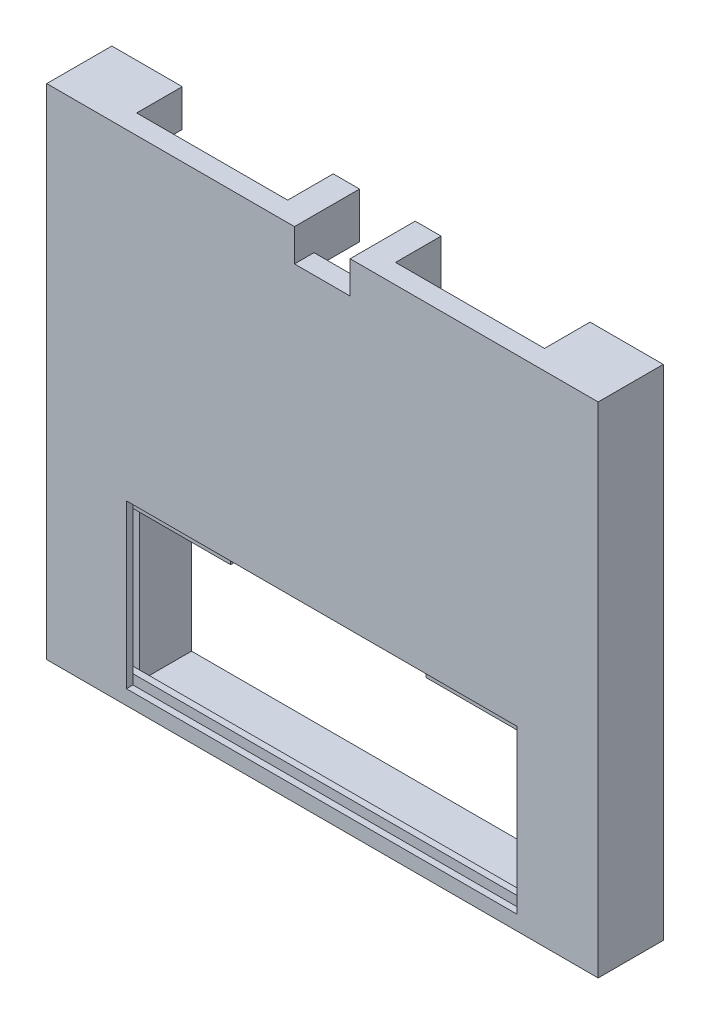
from build123d import *

# Parameters (mm, degrees)
SKETCH1_W           = 215.166666666
SKETCH1_H           = 194.666666667
BOSS_EXTRUDE1_DEPTH = 25.4
SKETCH2_R           = 5.08
CUT_EXTRUDE1_DEPTH  = 17.78
SKETCH3_W           = 152.4
SKETCH3_H           = 63.5
CUT_EXTRUDE2_DEPTH  = 26.4
SKETCH4_W           = 21.718207711
SKETCH4_H           = 12.612953238
CUT_EXTRUDE3_DEPTH  = 26.4
SKETCH6_W           = 38.1
SKETCH6_H           = 2.54
SKETCH6_W_2         = 38.074968348
BOSS_EXTRUDE2_DEPTH = 3.81
SKETCH8_W           = 152.4
SKETCH8_H           = 2.54
BOSS_EXTRUDE3_DEPTH = 3.81
SKETCH9_W           = 2.54
SKETCH9_H           = 55.88
CUT_EXTRUDE8_DEPTH  = 3.81
SKETCH10_W          = 10.102446857
SKETCH10_H          = 17.859023659
SKETCH10_W_2        = 10.26192437
BOSS_EXTRUDE4_DEPTH = 17.78


with BuildPart() as part:
    # Sketch1 → Boss-Extrude1 (new body)
    with BuildSketch(Plane.XY):
        with Locations((78, 82.448428597)):
            Rectangle(SKETCH1_W, SKETCH1_H)
    extrude(amount=BOSS_EXTRUDE1_DEPTH)

    # Sketch2 → Cut-Extrude1 (cut)
    with BuildSketch(Plane(origin=(0, 0, 0), x_dir=(-1, 0, 0), z_dir=(0, 0, -1))):
        with Locations((5.416666667, 47.03176193)):
            Circle(SKETCH2_R)
        with Locations((-161.416666667, 47.03176193)):
            Circle(SKETCH2_R)
        Polygon((2.114639597, 179.78176193), (-157.022787609, 179.78176193), (-157.022787609, 164.200846175), (-171.765480067, 164.200846175), (-171.765480067, 67.571945264), (-148.766666667, 67.571945264), (-91.83014353, 67.571945264), (-91.83014353, 31.6046473), (-66.159852528, 31.6046473), (-66.159852528, 67.571945264), (-7.233333333, 67.387956716), (16.581678434, 67.387956716), (16.581678434, 165.292698163), (2.114639597, 165.292698163), align=None)
    extrude(amount=-CUT_EXTRUDE1_DEPTH, mode=Mode.SUBTRACT)

    # Sketch3 → Cut-Extrude2 (cut, through all)
    with BuildSketch(Plane(origin=(0, 0, 0), x_dir=(-1, 0, 0), z_dir=(0, 0, -1))):
        with Locations((-77.714845761, 22.583067422)):
            Rectangle(SKETCH3_W, SKETCH3_H)
    extrude(amount=-CUT_EXTRUDE2_DEPTH, mode=Mode.SUBTRACT)

    # Sketch4 → Cut-Extrude3 (cut, through all)
    with BuildSketch(Plane(origin=(0, 0, 0), x_dir=(-1, 0, 0), z_dir=(0, 0, -1))):
        with Locations((-77.933490884, 173.475285311)):
            Rectangle(SKETCH4_W, SKETCH4_H)
    extrude(amount=-CUT_EXTRUDE3_DEPTH, mode=Mode.SUBTRACT)

    # Sketch6 → Boss-Extrude2 (add)
    with BuildSketch(Plane.XZ.offset(-54.333067422)):
        with Locations((20.564845761, 21.59)):
            Rectangle(SKETCH6_W, SKETCH6_H)
        with Locations((134.877361587, 21.59)):
            Rectangle(SKETCH6_W_2, SKETCH6_H)
    extrude(amount=BOSS_EXTRUDE2_DEPTH)

    # Sketch8 → Boss-Extrude3 (add)
    with BuildSketch(Plane(origin=(0, -9.166932578, 0), x_dir=(1, 0, 0), z_dir=(0, 1, 0))):
        with Locations((77.714845761, -21.59)):
            Rectangle(SKETCH8_W, SKETCH8_H)
    extrude(amount=BOSS_EXTRUDE3_DEPTH)

    # Sketch9 → Cut-Extrude8 (cut)
    with BuildSketch(Plane(origin=(1.514845761, 0, 0), x_dir=(0, 0, -1), z_dir=(1, 0, 0))):
        with Locations((-21.59, 22.583067422)):
            Rectangle(SKETCH9_W, SKETCH9_H)
    extrude(amount=-CUT_EXTRUDE8_DEPTH, mode=Mode.SUBTRACT)

    # Sketch10 → Boss-Extrude4 (add)
    with BuildSketch(Plane(origin=(0, 0, 17.78), x_dir=(-1, 0, 0), z_dir=(0, 0, -1))):
        with Locations((-93.843818168, 170.852250101)):
            Rectangle(SKETCH10_W, SKETCH10_H)
        with Locations((-61.943424843, 170.852250101)):
            Rectangle(SKETCH10_W_2, SKETCH10_H)
    extrude(amount=BOSS_EXTRUDE4_DEPTH)


solid = part.part
